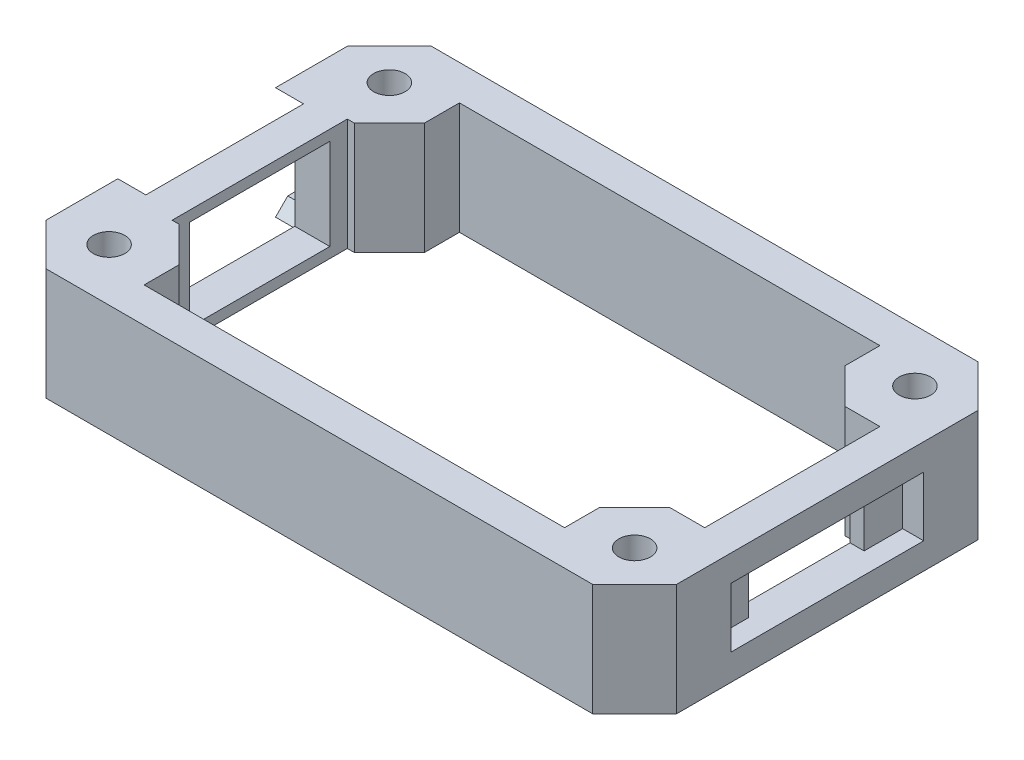
from build123d import *

# Parameters (mm, degrees)
SKETCH1_W            = 90
SKETCH1_H            = 55
BOSS_EXTRUDE1_DEPTH  = 16
SKETCH2_W            = 22
SKETCH2_H            = 1.75
SKETCH2_H_2          = 12.5
CUT_EXTRUDE1_DEPTH   = 4
SKETCH3_W            = 20
SKETCH3_H            = 13
CUT_EXTRUDE2_DEPTH   = 20
CHAMFER1_SIZE        = 6
M4_CLEARANCE_HOLE1_D = 4.5
SKETCH7_W            = 27.5
SKETCH7_H            = 8.5
CUT_EXTRUDE3_DEPTH   = 3
SKETCH8_W            = 16.5
SKETCH8_H            = 8.5
CUT_EXTRUDE4_DEPTH   = 12
SKETCH9_R            = 2.25
CUT_EXTRUDE5_DEPTH   = 17
CHAMFER2_SIZE        = 5


with BuildPart() as part:
    # Sketch1 → Boss-Extrude1 (new body)
    with BuildSketch(Plane(origin=(0, 0, 0), x_dir=(1, 0, 0), z_dir=(0, 1, 0))):
        Rectangle(SKETCH1_W, SKETCH1_H)
    extrude(amount=BOSS_EXTRUDE1_DEPTH)

    # Sketch2 → Cut-Extrude1 (cut)
    with BuildSketch(Plane.ZY.offset(45)):
        with Locations((0, 15.125)):
            Rectangle(SKETCH2_W, SKETCH2_H)
        Polygon((11, 16), (11, 14.25), (13, 14.25), (11.25, 16), align=None)
        Polygon((-11.25, 16), (-13, 14.25), (-11, 14.25), (-11, 16), align=None)
        Polygon((-17.5, 14.25), (-17.5, 1.75), (-13, 1.75), (-11, 1.75), (-11, 14.25), (-13, 14.25), align=None)
        with Locations((0, 8)):
            Rectangle(SKETCH2_W, SKETCH2_H_2)
        Polygon((11, 14.25), (11, 1.75), (13, 1.75), (17.5, 1.75), (17.5, 14.25), (13, 14.25), align=None)
        with Locations((0, 0.875)):
            Rectangle(SKETCH2_W, SKETCH2_H)
        Polygon((13, 1.75), (11, 1.75), (11, 0), (11.25, 0), align=None)
        Polygon((-11, 1.75), (-13, 1.75), (-11.25, 0), (-11, 0), align=None)
    extrude(amount=-CUT_EXTRUDE1_DEPTH, mode=Mode.SUBTRACT)

    # Sketch3 → Cut-Extrude2 (cut)
    with BuildSketch(Plane.ZY.offset(41)):
        with Locations((0, 8)):
            Rectangle(SKETCH3_W, SKETCH3_H)
    extrude(amount=-CUT_EXTRUDE2_DEPTH, mode=Mode.SUBTRACT)

    # Chamfer1
    chamfer1_edges = [part.edges().sort_by_distance(p)[0] for p in [
        (45, 8, 27.5),
        (-45, 8, 27.5),
        (-45, 8, -27.5),
        (45, 8, -27.5),
    ]]
    chamfer(chamfer1_edges, length=CHAMFER1_SIZE)

    # M4 Clearance Hole1 (through all)
    with Locations(Plane(origin=(0, 16, 0), x_dir=(1, 0, 0), z_dir=(0, 1, 0))):
        with Locations((0, 0), (37.5, 20), (-37.5, -20), (-37.5, 20), (37.5, -20)):
            Hole(M4_CLEARANCE_HOLE1_D / 2)

    # Sketch7 → Cut-Extrude3 (cut)
    with BuildSketch(Plane(origin=(45, 0, 0), x_dir=(0, 0, -1), z_dir=(1, 0, 0))):
        with Locations((0, 8)):
            Rectangle(SKETCH7_W, SKETCH7_H)
    extrude(amount=-CUT_EXTRUDE3_DEPTH, mode=Mode.SUBTRACT)

    # Sketch8 → Cut-Extrude4 (cut)
    with BuildSketch(Plane(origin=(42, 0, 0), x_dir=(0, 0, -1), z_dir=(1, 0, 0))):
        with Locations((0, 8)):
            Rectangle(SKETCH8_W, SKETCH8_H)
    extrude(amount=-CUT_EXTRUDE4_DEPTH, mode=Mode.SUBTRACT)

    # Sketch9 → Cut-Extrude5 (cut, through all)
    with BuildSketch(Plane(origin=(0, 16, 0), x_dir=(1, 0, 0), z_dir=(0, 1, 0))):
        Polygon((30, -12.5), (40, -12.5), (40, 12.5), (30, 12.5), (30, 22.5), (-30, 22.5), (-30, 12.5), (-36, 12.5), (-36, -12.5), (-30, -12.5), (-30, -22.5), (30, -22.5), align=None)
        Circle(SKETCH9_R, mode=Mode.SUBTRACT)
    extrude(amount=-CUT_EXTRUDE5_DEPTH, mode=Mode.SUBTRACT)

    # Chamfer2
    chamfer2_edges = [part.edges().sort_by_distance(p)[0] for p in [
        (30, 8, -12.5),
        (30, 8, 12.5),
        (-30, 8, 12.5),
        (-30, 8, -12.5),
    ]]
    chamfer(chamfer2_edges, length=CHAMFER2_SIZE)


solid = part.part
